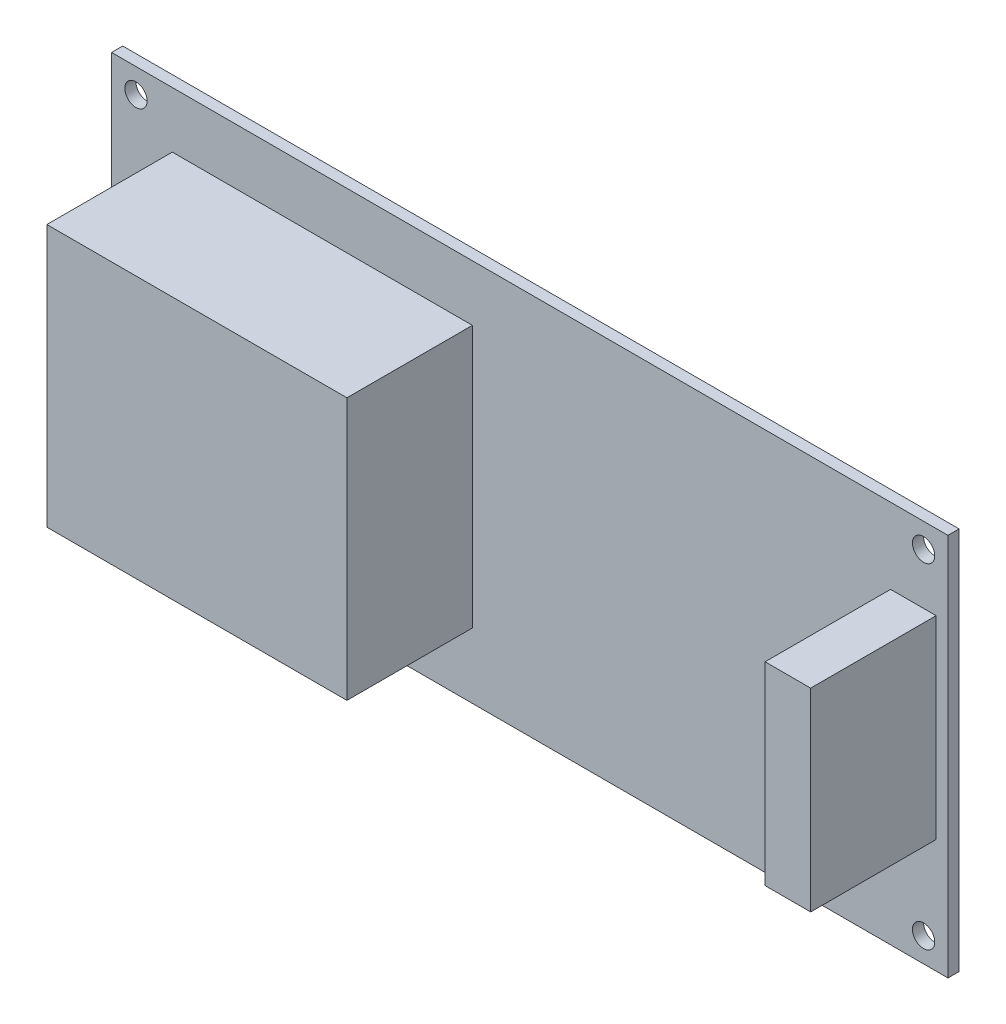
from build123d import *

# Parameters (mm, degrees)
ESQUISSE1_W        = 120
ESQUISSE1_H        = 55
ESQUISSE1_R        = 1.6
BOSS_EXTRU_1_DEPTH = 1.6
ESQUISSE2_W        = 43.050312428
ESQUISSE2_H        = 37.603564561
ESQUISSE2_W_2      = 6.539195339
ESQUISSE2_H_2      = 27.81484763
BOSS_EXTRU_2_DEPTH = 18


with BuildPart() as part:
    # Esquisse1 → Boss.-Extru.1 (new body)
    with BuildSketch(Plane.XY):
        Rectangle(ESQUISSE1_W, ESQUISSE1_H)
        with Locations((-56.5, 24)):
            Circle(ESQUISSE1_R, mode=Mode.SUBTRACT)
        with Locations((56.5, 24)):
            Circle(ESQUISSE1_R, mode=Mode.SUBTRACT)
        with Locations((56.5, -24)):
            Circle(ESQUISSE1_R, mode=Mode.SUBTRACT)
        with Locations((-56.5, -24)):
            Circle(ESQUISSE1_R, mode=Mode.SUBTRACT)
    extrude(amount=BOSS_EXTRU_1_DEPTH)

    # Esquisse2 → Boss.-Extru.2 (add)
    with BuildSketch(Plane.XY.offset(1.6)):
        with Locations((-29.757687253, 0.675058423)):
            Rectangle(ESQUISSE2_W, ESQUISSE2_H)
        with Locations((55.030096994, 2.76225902)):
            Rectangle(ESQUISSE2_W_2, ESQUISSE2_H_2)
    extrude(amount=BOSS_EXTRU_2_DEPTH)


solid = part.part
